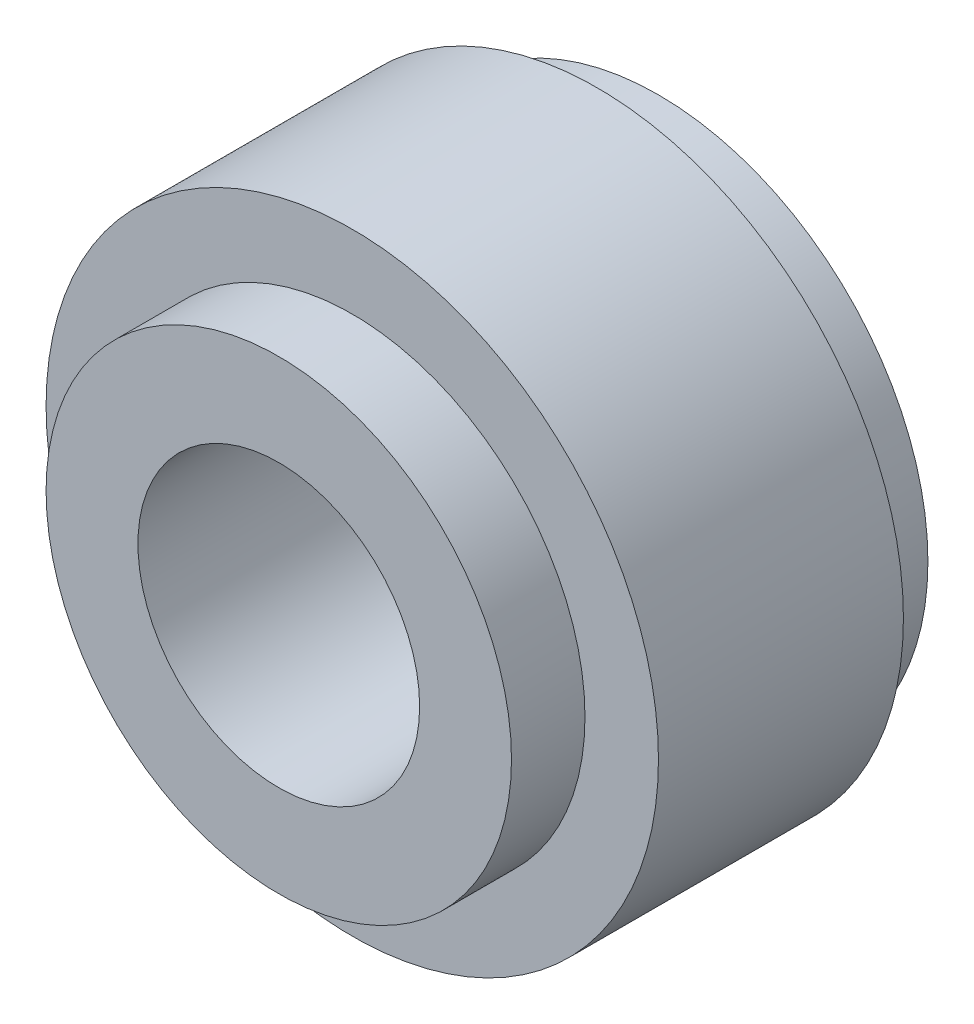
from build123d import *

# Parameters (mm, degrees)
SKETCH1_R           = 25
BOSS_EXTRUDE1_DEPTH = 20
SKETCH2_R           = 19
BOSS_EXTRUDE2_DEPTH = 6
SKETCH3_R           = 11.5
CUT_EXTRUDE1_DEPTH  = 60
SKETCH5_R           = 22
SKETCH5_R_2         = 11.5
BOSS_EXTRUDE4_DEPTH = 5


with BuildPart() as part:
    # Sketch1 → Boss-Extrude1 (new body)
    with BuildSketch(Plane.XY):
        Circle(SKETCH1_R)
    extrude(amount=BOSS_EXTRUDE1_DEPTH)

    # Sketch2 → Boss-Extrude2 (add)
    with BuildSketch(Plane.XY.offset(20)):
        Circle(SKETCH2_R)
    extrude(amount=BOSS_EXTRUDE2_DEPTH)

    # Sketch3 → Cut-Extrude1 (cut)
    with BuildSketch(Plane.XY.offset(26)):
        Circle(SKETCH3_R)
    extrude(amount=-CUT_EXTRUDE1_DEPTH, mode=Mode.SUBTRACT)

    # Sketch5 → Boss-Extrude4 (add)
    with BuildSketch(Plane(origin=(0, 0, 0), x_dir=(-1, 0, 0), z_dir=(0, 0, -1))):
        Circle(SKETCH5_R)
        with Locations(Location((0, 0, 0), (0, 0, 180))):
            Circle(SKETCH5_R_2, mode=Mode.SUBTRACT)
    extrude(amount=BOSS_EXTRUDE4_DEPTH)


solid = part.part
